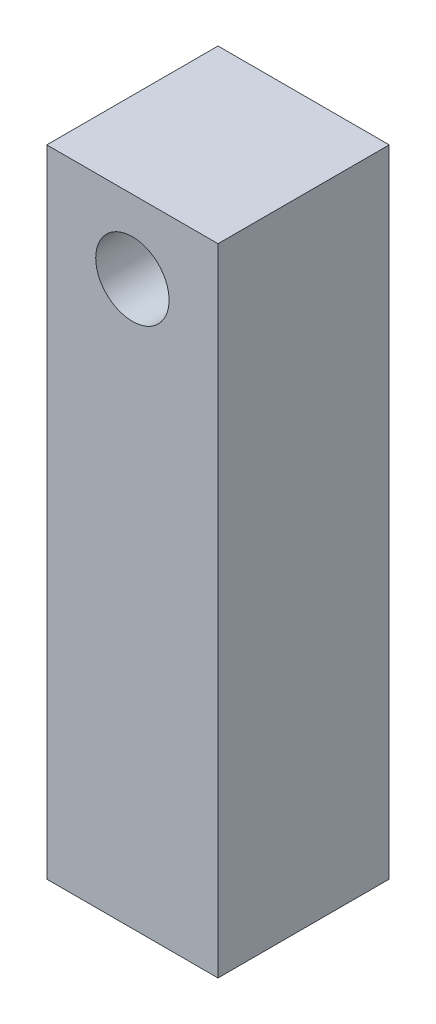
from build123d import *

# Parameters (mm, degrees)
SKETCH1_W                       = 7
SKETCH1_H                       = 7
SKETCH1_R                       = 2
BOSS_EXTRUDE1_DEPTH             = 20
BOSS_EXTRUDE2_REACH             = 5.5
SKETCH2_W                       = 7
SKETCH2_H                       = 6
SKETCH2_R                       = 1.5
BOSS_EXTRUDE2_DIRECTION_2_REACH = 5.5


with BuildPart() as part:
    # Sketch1 → Boss-Extrude1 (new body)
    with BuildSketch(Plane(origin=(0, 0, 0), x_dir=(1, 0, 0), z_dir=(0, 1, 0))):
        Rectangle(SKETCH1_W, SKETCH1_H)
        Circle(SKETCH1_R, mode=Mode.SUBTRACT)
    extrude(amount=BOSS_EXTRUDE1_DEPTH)

    # Boss-Extrude2: up to this face of the body (flat: up to its plane)
    boss_extrude2_end = Plane(part.part.faces().sort_by_distance((0, 10, 3.5))[0])
    # Sketch2 → Boss-Extrude2 (add, up to the picked face)
    with BuildSketch(Plane.XY, mode=Mode.PRIVATE) as boss_extrude2_sk1:
        with Locations((0, 23)):
            Rectangle(SKETCH2_W, SKETCH2_H)
        with Locations((0, 23)):
            Circle(SKETCH2_R, mode=Mode.SUBTRACT)
    boss_extrude2_tool1 = split(extrude(boss_extrude2_sk1.sketch, amount=BOSS_EXTRUDE2_REACH, mode=Mode.PRIVATE), bisect_by=boss_extrude2_end, keep=Keep.BOTH, mode=Mode.PRIVATE)
    add(boss_extrude2_tool1.solids().sort_by_distance((0, 25.907805, 0))[0])

    # Boss-Extrude2 direction 2: up to this face of the body (flat: up to its plane)
    boss_extrude2_direction_2_end = Plane(part.part.faces().sort_by_distance((0, 10, -3.5))[0])
    # Sketch2 → Boss-Extrude2 direction 2 (add, up to the picked face)
    with BuildSketch(Plane.XY, mode=Mode.PRIVATE) as boss_extrude2_direction_2_sk1:
        with Locations((0, 23)):
            Rectangle(SKETCH2_W, SKETCH2_H)
        with Locations((0, 23)):
            Circle(SKETCH2_R, mode=Mode.SUBTRACT)
    boss_extrude2_direction_2_tool1 = split(extrude(boss_extrude2_direction_2_sk1.sketch, amount=-BOSS_EXTRUDE2_DIRECTION_2_REACH, mode=Mode.PRIVATE), bisect_by=boss_extrude2_direction_2_end, keep=Keep.BOTH, mode=Mode.PRIVATE)
    add(boss_extrude2_direction_2_tool1.solids().sort_by_distance((0, 25.907805, 0))[0])


solid = part.part
